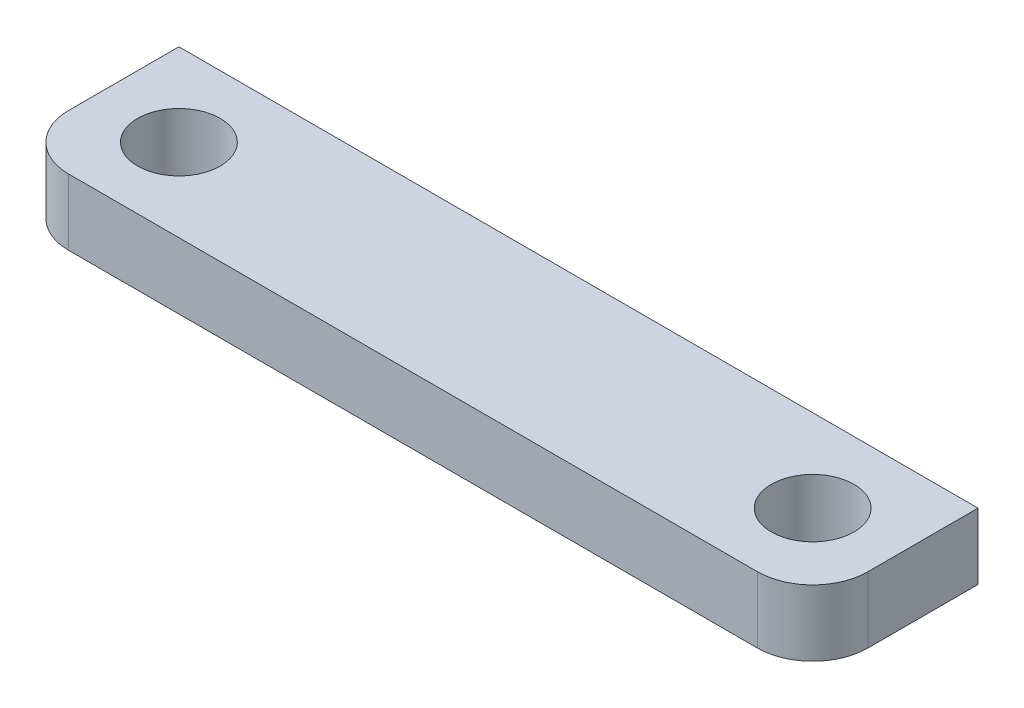
from build123d import *

# Parameters (mm, degrees)
SKETCH1_W           = 29
SKETCH1_H           = 6
BOSS_EXTRUDE1_DEPTH = 2.4
SKETCH2_R           = 1.5
CUT_EXTRUDE1_DEPTH  = 2.4
FILLET1_R           = 2


with BuildPart() as part:
    # Sketch1 → Boss-Extrude1 (new body)
    with BuildSketch(Plane(origin=(0, 0, 0), x_dir=(1, 0, 0), z_dir=(0, 1, 0))):
        with Locations((14.5, -3)):
            Rectangle(SKETCH1_W, SKETCH1_H)
    extrude(amount=BOSS_EXTRUDE1_DEPTH)

    # Sketch2 → Cut-Extrude1 (cut)
    with BuildSketch(Plane(origin=(0, 2.4, 0), x_dir=(1, 0, 0), z_dir=(0, 1, 0))):
        with Locations((3, -3)):
            Circle(SKETCH2_R)
        with Locations((26, -3)):
            Circle(SKETCH2_R)
    extrude(amount=-CUT_EXTRUDE1_DEPTH, mode=Mode.SUBTRACT)

    # Fillet1
    fillet1_edges = [part.edges().sort_by_distance(p)[0] for p in [
        (29, 1.2, 6),
        (0, 1.2, 6),
    ]]
    fillet(fillet1_edges, radius=FILLET1_R)


solid = part.part
